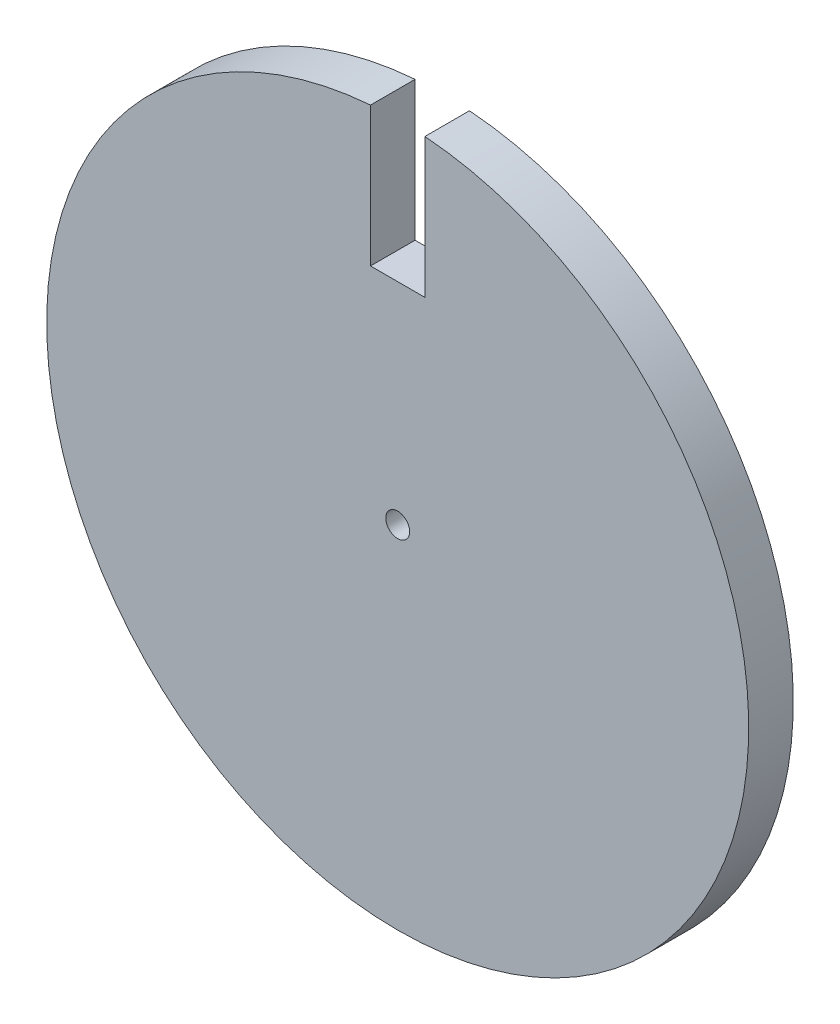
from build123d import *

# Parameters (mm, degrees)
SKETCH1_R           = 25
SKETCH1_R_2         = 0.85
BOSS_EXTRUDE1_DEPTH = 1.5875
CUT_EXTRUDE1_REACH  = 5.175
SKETCH2_W           = 3.873993702
SKETCH2_H           = 19.044786736


with BuildPart() as part:
    # Sketch1 → Boss-Extrude1 (new body, symmetric)
    with BuildSketch(Plane.XY):
        Circle(SKETCH1_R)
        Circle(SKETCH1_R_2, mode=Mode.SUBTRACT)
    extrude(amount=BOSS_EXTRUDE1_DEPTH, both=True)

    # Sketch2 → Cut-Extrude1 (cut, up to next)
    with BuildSketch(Plane(origin=(0, 0, -1.5875), x_dir=(-1, 0, 0), z_dir=(0, 0, -1)), mode=Mode.PRIVATE) as cut_extrude1_sk1:
        with Locations((0, 24.522393368)):
            Rectangle(SKETCH2_W, SKETCH2_H)
    cut_extrude1_tool1 = extrude(cut_extrude1_sk1.sketch, amount=-CUT_EXTRUDE1_REACH, mode=Mode.PRIVATE) & part.part
    add(cut_extrude1_tool1.solids().sort_by_distance((0, 24.522393, -1.5875))[0], mode=Mode.SUBTRACT)


solid = part.part
